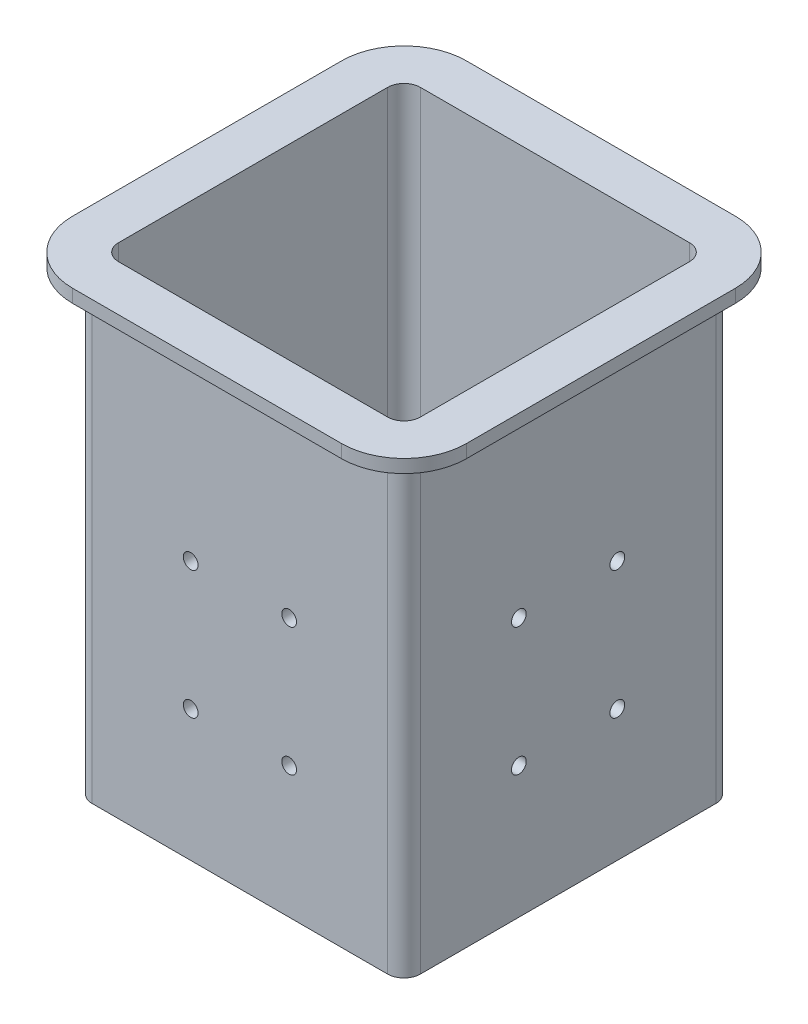
from build123d import *

# Parameters (mm, degrees)
SKETCH1_W           = 100
SKETCH1_H           = 100
SKETCH1_R           = 10
SKETCH1_R_2         = 2.75
BOSS_EXTRUDE1_DEPTH = 4
SKETCH2_W           = 100
SKETCH2_H           = 100
SKETCH2_W_2         = 92
SKETCH2_H_2         = 92
BOSS_EXTRUDE2_DEPTH = 135
FILLET1_R           = 5
BOSS_EXTRUDE3_DEPTH = 4
FILLET2_R           = 2
CUT_EXTRUDE1_REACH  = 112
SKETCH4_R           = 2.25
CUT_EXTRUDE2_REACH  = 112
SKETCH5_R           = 2.25


with BuildPart() as part:
    # Sketch1 → Boss-Extrude1 (new body)
    with BuildSketch(Plane(origin=(0, 0, 0), x_dir=(1, 0, 0), z_dir=(0, 1, 0))):
        Rectangle(SKETCH1_W, SKETCH1_H)
        Circle(SKETCH1_R, mode=Mode.SUBTRACT)
        with Locations((33.45, 33.45)):
            Circle(SKETCH1_R_2, mode=Mode.SUBTRACT)
        with Locations((33.45, -33.45)):
            Circle(SKETCH1_R_2, mode=Mode.SUBTRACT)
        with Locations((-33.45, -33.45)):
            Circle(SKETCH1_R_2, mode=Mode.SUBTRACT)
        with Locations((-33.45, 33.45)):
            Circle(SKETCH1_R_2, mode=Mode.SUBTRACT)
    extrude(amount=BOSS_EXTRUDE1_DEPTH)

    # Sketch2 → Boss-Extrude2 (add)
    with BuildSketch(Plane(origin=(0, 4, 0), x_dir=(1, 0, 0), z_dir=(0, 1, 0))):
        Rectangle(SKETCH2_W, SKETCH2_H)
        Rectangle(SKETCH2_W_2, SKETCH2_H_2, mode=Mode.SUBTRACT)
    extrude(amount=BOSS_EXTRUDE2_DEPTH)

    # Fillet1
    fillet1_edges = [part.edges().sort_by_distance(p)[0] for p in [
        (-46, 71.5, 46),
        (46, 71.5, 46),
        (46, 71.5, -46),
        (-46, 71.5, -46),
        (-50, 69.5, -50),
        (50, 69.5, -50),
        (50, 69.5, 50),
        (-50, 69.5, 50),
    ]]
    fillet(fillet1_edges, radius=FILLET1_R)

    # Sketch3 → Boss-Extrude3 (add)
    with BuildSketch(Plane(origin=(0, 139, 0), x_dir=(1, 0, 0), z_dir=(0, 1, 0))):
        with BuildLine():
            Line((-41, 60), (41, 60))
            ThreePointArc((41, 60), (54.435028843, 54.435028843), (60, 41))
            Line((60, 41), (60, -41))
            ThreePointArc((60, -41), (54.435028843, -54.435028843), (41, -60))
            Line((41, -60), (-41, -60))
            ThreePointArc((-41, -60), (-54.435028843, -54.435028843), (-60, -41))
            Line((-60, -41), (-60, 41))
            ThreePointArc((-60, 41), (-54.435028843, 54.435028843), (-41, 60))
        make_face()
        with BuildLine():
            Line((-41, 46), (41, 46))
            ThreePointArc((41, 46), (44.535533906, 44.535533906), (46, 41))
            Line((46, 41), (46, -41))
            ThreePointArc((46, -41), (44.535533906, -44.535533906), (41, -46))
            Line((41, -46), (-41, -46))
            ThreePointArc((-41, -46), (-44.535533906, -44.535533906), (-46, -41))
            Line((-46, -41), (-46, 41))
            ThreePointArc((-46, 41), (-44.535533906, 44.535533906), (-41, 46))
        make_face(mode=Mode.SUBTRACT)
    extrude(amount=BOSS_EXTRUDE3_DEPTH)

    # Fillet2
    fillet2_edges = [part.edges().sort_by_distance(p)[0] for p in [
        (0, 139, 50),
        (-50, 139, 0),
        (50, 139, 0),
        (0, 139, -50),
        (-48.535533906, 139, -48.535533906),
        (48.535533906, 139, -48.535533906),
        (48.535533906, 139, 48.535533906),
        (-48.535533906, 139, 48.535533906),
    ]]
    fillet(fillet2_edges, radius=FILLET2_R)

    # Sketch4 → Cut-Extrude1 (cut, up to next)
    with BuildSketch(Plane(origin=(50, 0, 0), x_dir=(0, 0, -1), z_dir=(1, 0, 0)), mode=Mode.PRIVATE) as cut_extrude1_sk1:
        with Locations((-15, 79)):
            Circle(SKETCH4_R)
    cut_extrude1_tool1 = extrude(cut_extrude1_sk1.sketch, amount=-CUT_EXTRUDE1_REACH, mode=Mode.PRIVATE) & part.part
    add(cut_extrude1_tool1.solids().sort_by_distance((50, 79, 15))[0], mode=Mode.SUBTRACT)
    # Sketch4 → Cut-Extrude1 (cut, up to next)
    with BuildSketch(Plane(origin=(50, 0, 0), x_dir=(0, 0, -1), z_dir=(1, 0, 0)), mode=Mode.PRIVATE) as cut_extrude1_sk2:
        with Locations((15, 79)):
            Circle(SKETCH4_R)
    cut_extrude1_tool2 = extrude(cut_extrude1_sk2.sketch, amount=-CUT_EXTRUDE1_REACH, mode=Mode.PRIVATE) & part.part
    add(cut_extrude1_tool2.solids().sort_by_distance((50, 79, -15))[0], mode=Mode.SUBTRACT)
    # Sketch4 → Cut-Extrude1 (cut, up to next)
    with BuildSketch(Plane(origin=(50, 0, 0), x_dir=(0, 0, -1), z_dir=(1, 0, 0)), mode=Mode.PRIVATE) as cut_extrude1_sk3:
        with Locations((15, 40)):
            Circle(SKETCH4_R)
    cut_extrude1_tool3 = extrude(cut_extrude1_sk3.sketch, amount=-CUT_EXTRUDE1_REACH, mode=Mode.PRIVATE) & part.part
    add(cut_extrude1_tool3.solids().sort_by_distance((50, 40, -15))[0], mode=Mode.SUBTRACT)
    # Sketch4 → Cut-Extrude1 (cut, up to next)
    with BuildSketch(Plane(origin=(50, 0, 0), x_dir=(0, 0, -1), z_dir=(1, 0, 0)), mode=Mode.PRIVATE) as cut_extrude1_sk4:
        with Locations((-15, 40)):
            Circle(SKETCH4_R)
    cut_extrude1_tool4 = extrude(cut_extrude1_sk4.sketch, amount=-CUT_EXTRUDE1_REACH, mode=Mode.PRIVATE) & part.part
    add(cut_extrude1_tool4.solids().sort_by_distance((50, 40, 15))[0], mode=Mode.SUBTRACT)

    # Sketch5 → Cut-Extrude2 (cut, up to next)
    with BuildSketch(Plane.XY.offset(50), mode=Mode.PRIVATE) as cut_extrude2_sk1:
        with Locations((15, 79)):
            Circle(SKETCH5_R)
    cut_extrude2_tool1 = extrude(cut_extrude2_sk1.sketch, amount=-CUT_EXTRUDE2_REACH, mode=Mode.PRIVATE) & part.part
    add(cut_extrude2_tool1.solids().sort_by_distance((15, 79, 50))[0], mode=Mode.SUBTRACT)
    # Sketch5 → Cut-Extrude2 (cut, up to next)
    with BuildSketch(Plane.XY.offset(50), mode=Mode.PRIVATE) as cut_extrude2_sk2:
        with Locations((-15, 79)):
            Circle(SKETCH5_R)
    cut_extrude2_tool2 = extrude(cut_extrude2_sk2.sketch, amount=-CUT_EXTRUDE2_REACH, mode=Mode.PRIVATE) & part.part
    add(cut_extrude2_tool2.solids().sort_by_distance((-15, 79, 50))[0], mode=Mode.SUBTRACT)
    # Sketch5 → Cut-Extrude2 (cut, up to next)
    with BuildSketch(Plane.XY.offset(50), mode=Mode.PRIVATE) as cut_extrude2_sk3:
        with Locations((-15, 40)):
            Circle(SKETCH5_R)
    cut_extrude2_tool3 = extrude(cut_extrude2_sk3.sketch, amount=-CUT_EXTRUDE2_REACH, mode=Mode.PRIVATE) & part.part
    add(cut_extrude2_tool3.solids().sort_by_distance((-15, 40, 50))[0], mode=Mode.SUBTRACT)
    # Sketch5 → Cut-Extrude2 (cut, up to next)
    with BuildSketch(Plane.XY.offset(50), mode=Mode.PRIVATE) as cut_extrude2_sk4:
        with Locations((15, 40)):
            Circle(SKETCH5_R)
    cut_extrude2_tool4 = extrude(cut_extrude2_sk4.sketch, amount=-CUT_EXTRUDE2_REACH, mode=Mode.PRIVATE) & part.part
    add(cut_extrude2_tool4.solids().sort_by_distance((15, 40, 50))[0], mode=Mode.SUBTRACT)


solid = part.part
